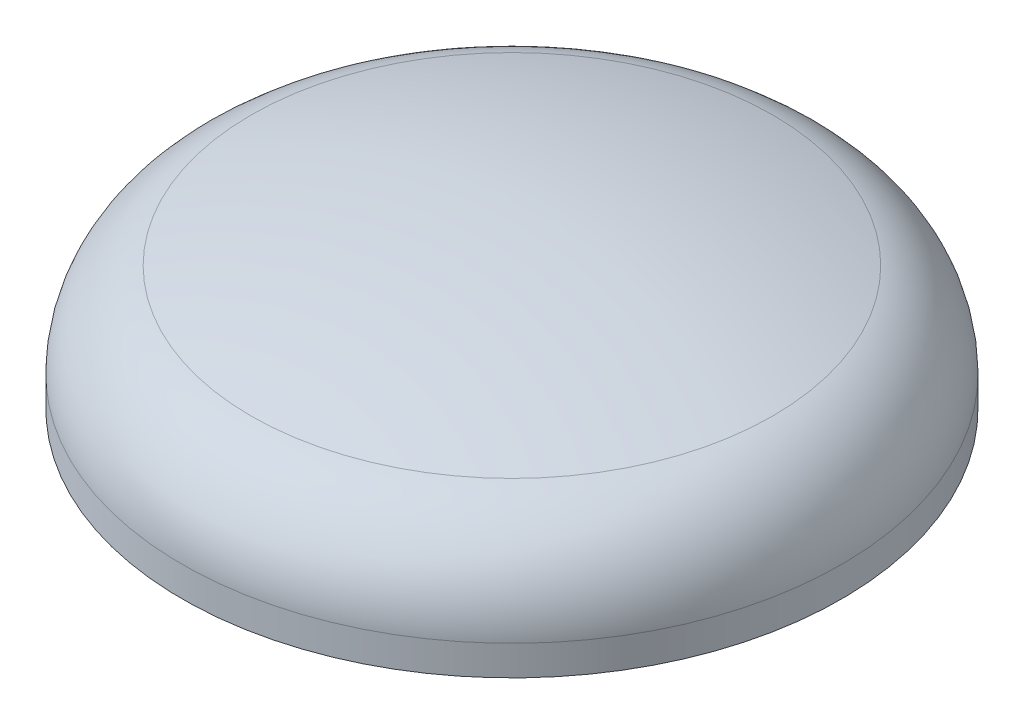
from build123d import *


with BuildPart() as part:
    # Croquis1 → Revolución1 (revolve)
    with BuildSketch(Plane(origin=(0, 0, 0), x_dir=(0, 0, -1), z_dir=(1, 0, 0))):
        with BuildLine():
            Line((0, 0), (0, 0.25))
            ThreePointArc((0, 0.25), (0.200214836, 0.234489789), (0.395652174, 0.18832926))
            ThreePointArc((0.395652174, 0.18832926), (0.471135928, 0.133910289), (0.5, 0.045445115))
            Line((0.5, 0.045445115), (0.5, 0))
            Line((0.5, 0), (0, 0))
        make_face()
    revolve(axis=Axis((0, 0, 0), (0, 1, 0)))


solid = part.part
